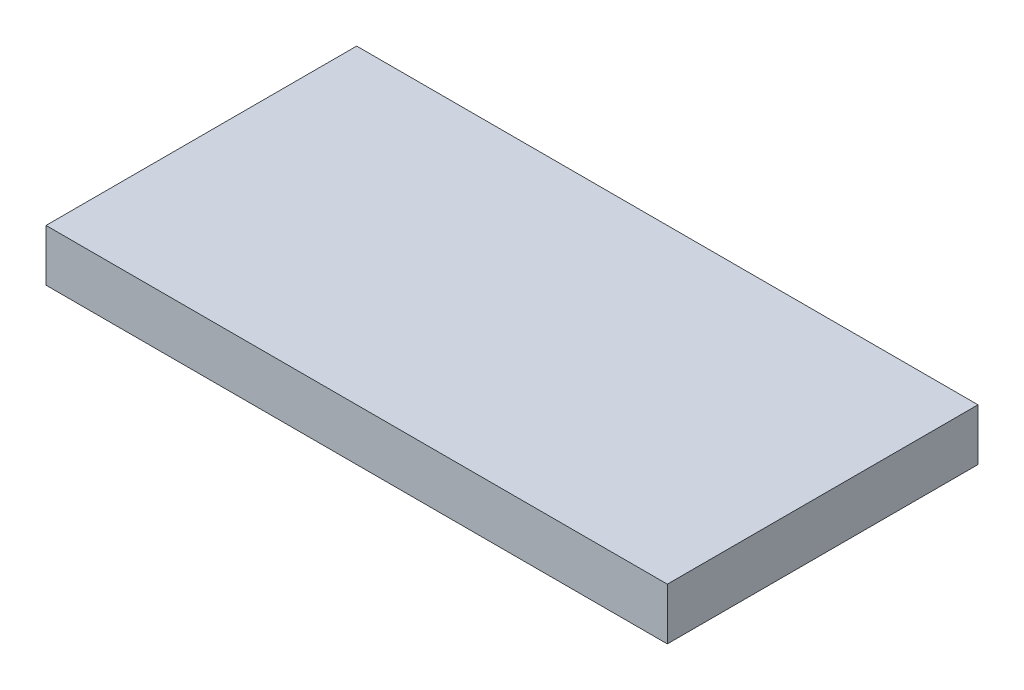
from build123d import *

# Parameters (mm, degrees)
SKETCH1_W           = 60
SKETCH1_H           = 30
BOSS_EXTRUDE1_DEPTH = 5


with BuildPart() as part:
    # Sketch1 → Boss-Extrude1 (new body)
    with BuildSketch(Plane(origin=(0, 0, 0), x_dir=(1, 0, 0), z_dir=(0, 1, 0))):
        with Locations((30, 15)):
            Rectangle(SKETCH1_W, SKETCH1_H)
    extrude(amount=BOSS_EXTRUDE1_DEPTH)


solid = part.part
